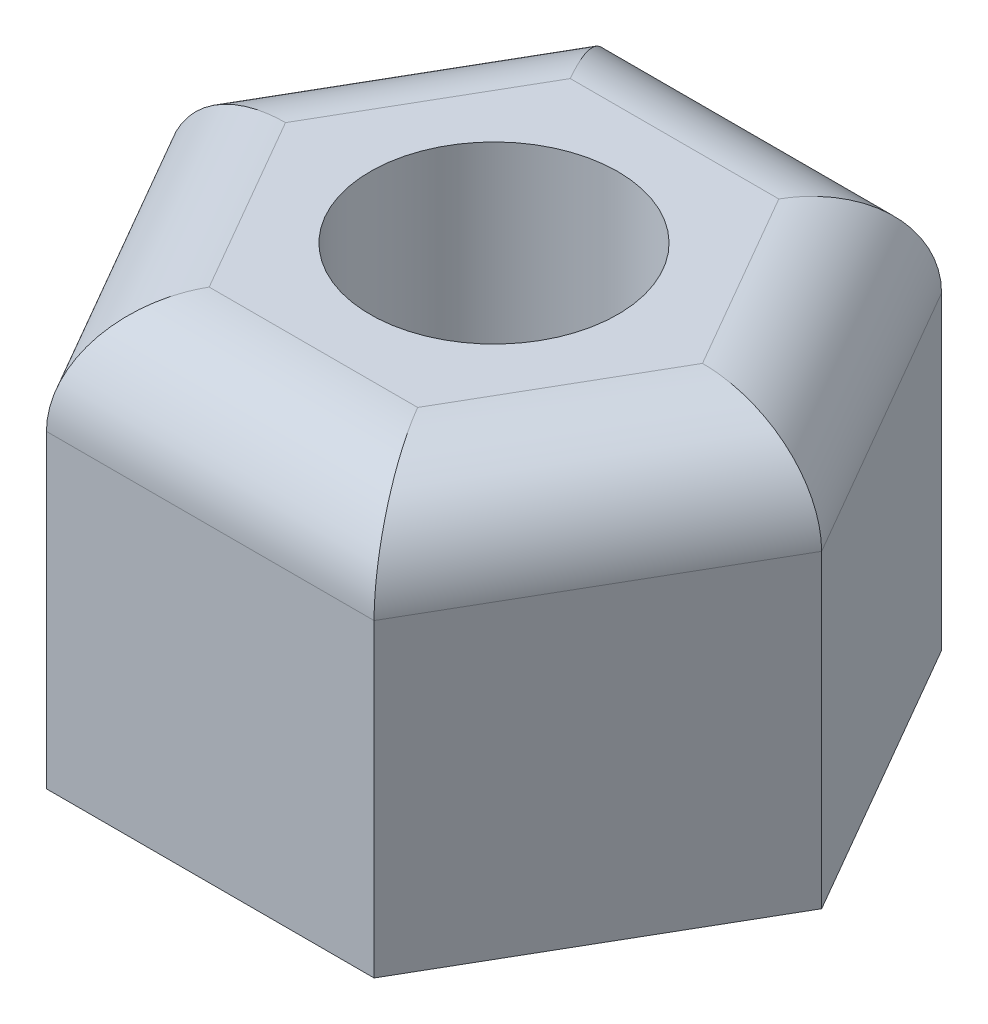
from build123d import *

# Parameters (mm, degrees)
BOSS_EXTRUDE2_DEPTH = 4
FILLET1_R           = 1
SKETCH3_R           = 1.2
CUT_EXTRUDE1_DEPTH  = 5


with BuildPart() as part:
    # Sketch2 → Boss-Extrude2 (new body)
    with BuildSketch(Plane(origin=(0, 0, 0), x_dir=(1, 0, 0), z_dir=(0, 1, 0))):
        Polygon((3.175426481, 0), (1.58771324, 2.75), (-1.58771324, 2.75), (-3.175426481, 0), (-1.58771324, -2.75), (1.58771324, -2.75), align=None)
    extrude(amount=BOSS_EXTRUDE2_DEPTH)

    # Fillet1
    fillet1_edges = [part.edges().sort_by_distance(p)[0] for p in [
        (0, 4, -2.75),
        (-2.38156986, 4, -1.375),
        (-2.38156986, 4, 1.375),
        (0, 4, 2.75),
        (2.38156986, 4, 1.375),
        (2.38156986, 4, -1.375),
    ]]
    fillet(fillet1_edges, radius=FILLET1_R)

    # Sketch3 → Cut-Extrude1 (cut, through all)
    with BuildSketch(Plane.XZ):
        Circle(SKETCH3_R)
    extrude(amount=-CUT_EXTRUDE1_DEPTH, mode=Mode.SUBTRACT)


solid = part.part
